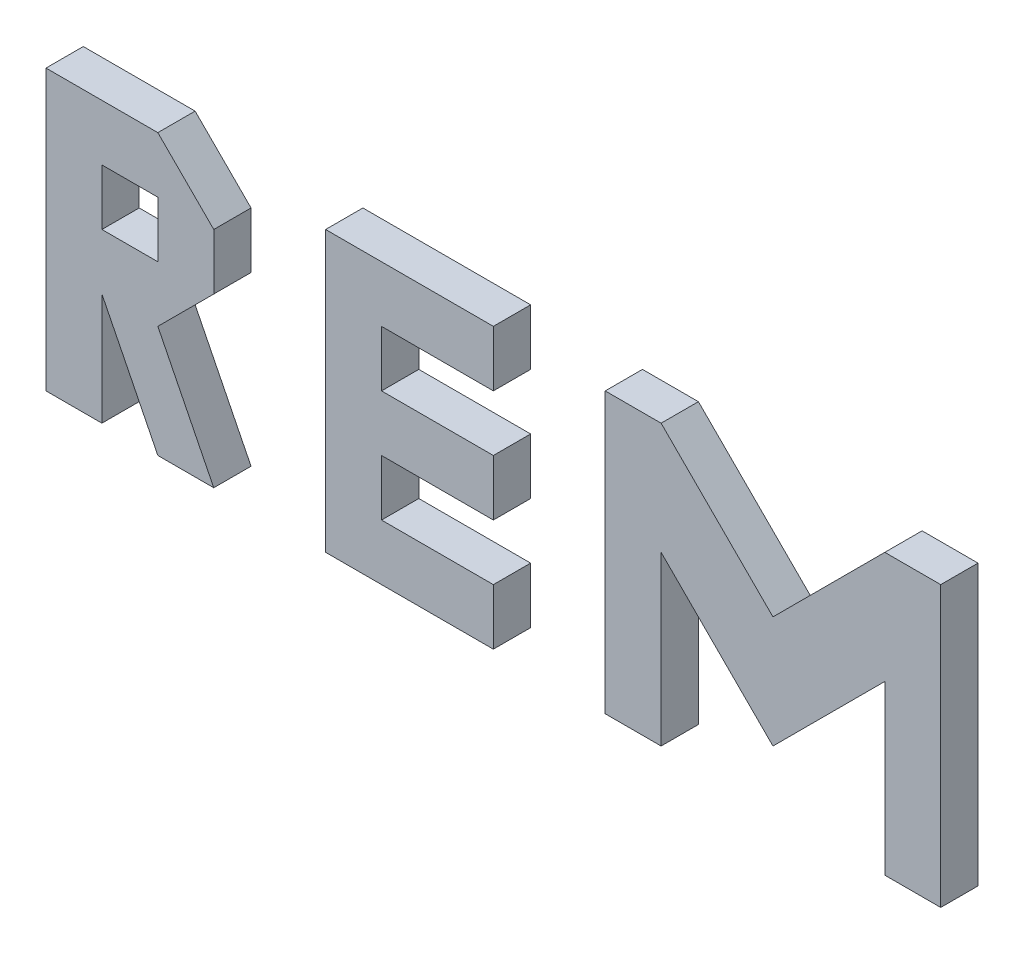
from build123d import *

# Parameters (mm, degrees)
SKETCH1_W        = 15
SKETCH1_H        = 15
EXTRUDE1_DEPTH   = 10
EXTRUDE1_2_DEPTH = 10
EXTRUDE1_3_DEPTH = 10


with BuildPart() as part:
    # Sketch1 → Extrude1 (new body)
    with BuildSketch(Plane.XY):
        Polygon((15, 0), (15, 30), (30, 0), (45, 0), (30, 30), (45, 45), (45, 60), (30, 75), (0, 75), (0, 0), align=None)
        with Locations((22.5, 52.5)):
            Rectangle(SKETCH1_W, SKETCH1_H, mode=Mode.SUBTRACT)
    extrude(amount=EXTRUDE1_DEPTH)


with BuildPart() as body_2:
    # Sketch1 → Extrude1 2 (new body)
    with BuildSketch(Plane.XY):
        Polygon((240, 0), (240, 75), (225, 75), (195, 45), (165, 75), (150, 75), (150, 0), (165, 0), (165, 45), (195, 15), (225, 45), (225, 0), align=None)
    extrude(amount=EXTRUDE1_2_DEPTH)


with BuildPart() as body_3:
    # Sketch1 → Extrude1 3 (new body)
    with BuildSketch(Plane.XY):
        Polygon((75, 0), (75, 75), (120, 75), (120, 60), (90, 60), (90, 45), (120, 45), (120, 30), (90, 30), (90, 15), (120, 15), (120, 0), align=None)
    extrude(amount=EXTRUDE1_3_DEPTH)


solid = Compound([part.part, body_2.part, body_3.part])
